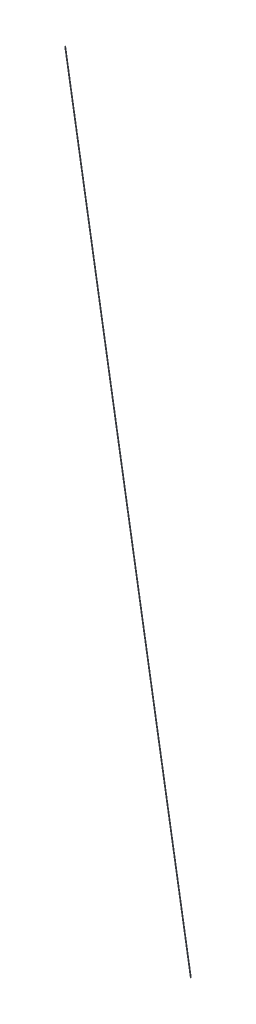
from build123d import *

# Parameters (mm, degrees)
SWEEP_1_PROFILE_R = 0.5


with BuildPart() as part:
    # 扫描1: sweep along a path in 草图3
    with BuildLine(Plane(origin=(0, 0, 0), x_dir=(0, 0, -1), z_dir=(1, 0, 0))) as sweep_1_path:
        Line((0, 0), (-217.5, 1505))
    # 扫描1 profile (on start of the path) → 扫描1 (sweep)
    with BuildSketch(Plane(origin=(0, 0, 0), x_dir=(0, -0.143032338, 0.989718016), z_dir=(0, 0.989718016, 0.143032338))):
        Circle(SWEEP_1_PROFILE_R)
    sweep(path=sweep_1_path.line)


solid = part.part
